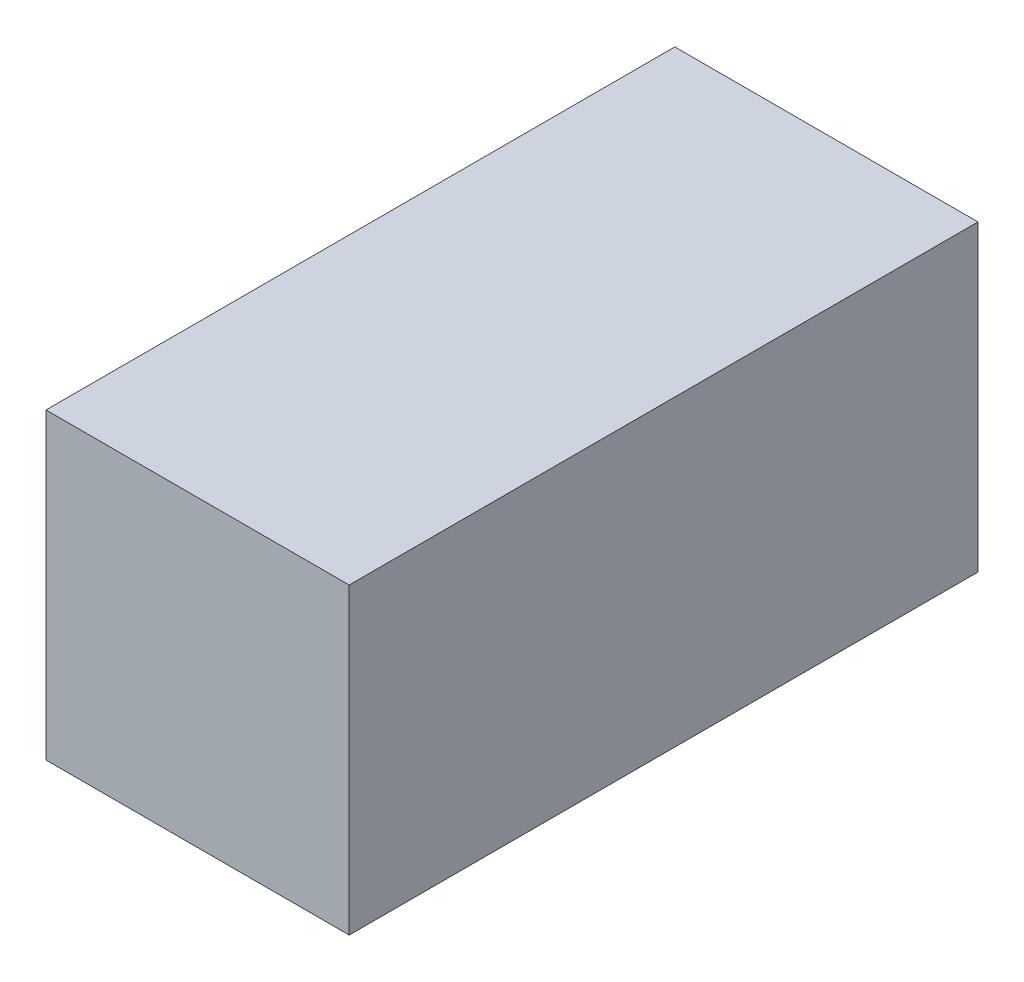
from build123d import *

# Parameters (mm, degrees)
SKETCH1_W           = 100
SKETCH1_H           = 207.407
BOSS_EXTRUDE1_DEPTH = 100


with BuildPart() as part:
    # Sketch1 → Boss-Extrude1 (new body)
    with BuildSketch(Plane(origin=(0, 0, 0), x_dir=(1, 0, 0), z_dir=(0, 1, 0))):
        Rectangle(SKETCH1_W, SKETCH1_H)
    extrude(amount=BOSS_EXTRUDE1_DEPTH)


solid = part.part
